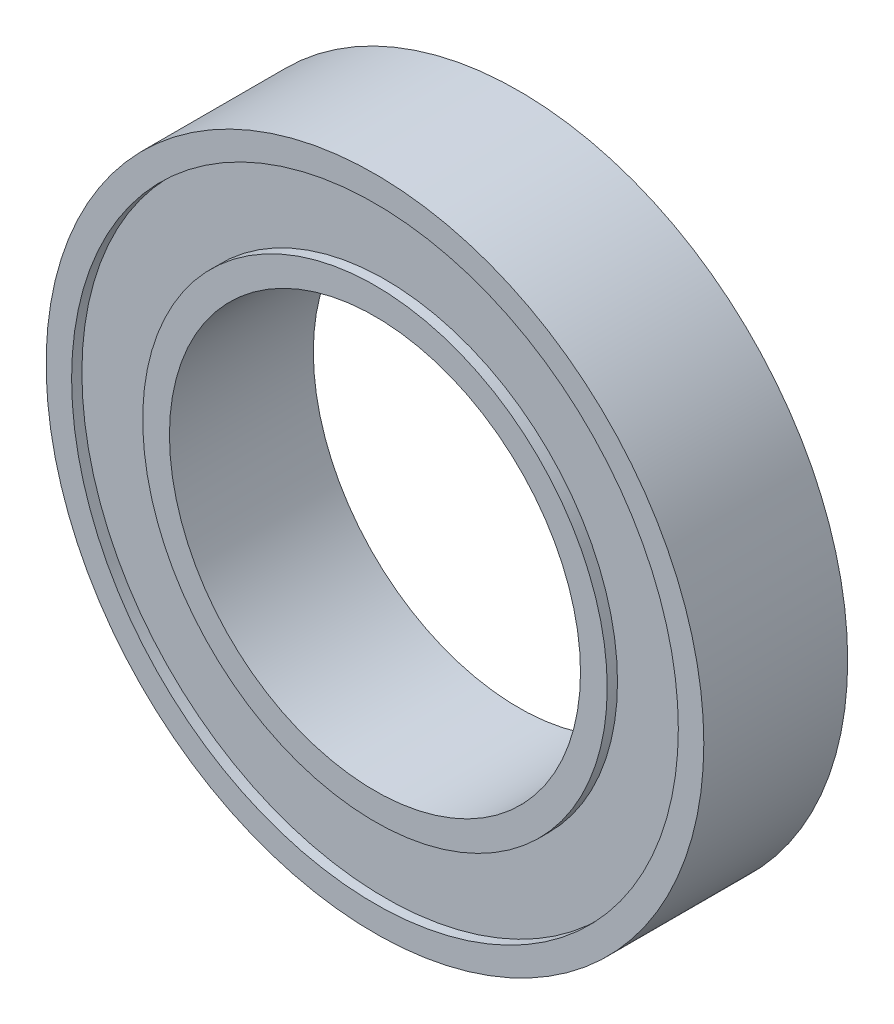
from build123d import *

# Parameters (mm, degrees)
SKETCH_1_R          = 16
EXTRUDE_1_DEPTH     = 7
SKETCH_2_R          = 10
CUT_EXTRUDE_1_DEPTH = 8
SKETCH_3_R          = 14.76
SKETCH_3_R_2        = 11.3
CUT_EXTRUDE_2_DEPTH = 0.5
SKETCH_4_R          = 14.76
SKETCH_4_R_2        = 11.3
CUT_EXTRUDE_3_DEPTH = 0.5


with BuildPart() as part:
    # 草圖1 → 填料-伸長1 (new body)
    with BuildSketch(Plane.XY):
        Circle(SKETCH_1_R)
    extrude(amount=EXTRUDE_1_DEPTH)

    # 草圖2 → 除料-伸長1 (cut, through all)
    with BuildSketch(Plane.XY.offset(7)):
        Circle(SKETCH_2_R)
    extrude(amount=-CUT_EXTRUDE_1_DEPTH, mode=Mode.SUBTRACT)

    # 草圖3 → 除料-伸長2 (cut)
    with BuildSketch(Plane.XY.offset(7)):
        Circle(SKETCH_3_R)
        Circle(SKETCH_3_R_2, mode=Mode.SUBTRACT)
    extrude(amount=-CUT_EXTRUDE_2_DEPTH, mode=Mode.SUBTRACT)

    # 草圖4 → 除料-伸長3 (cut)
    with BuildSketch(Plane(origin=(0, 0, 0), x_dir=(-1, 0, 0), z_dir=(0, 0, -1))):
        Circle(SKETCH_4_R)
        Circle(SKETCH_4_R_2, mode=Mode.SUBTRACT)
    extrude(amount=-CUT_EXTRUDE_3_DEPTH, mode=Mode.SUBTRACT)


solid = part.part
